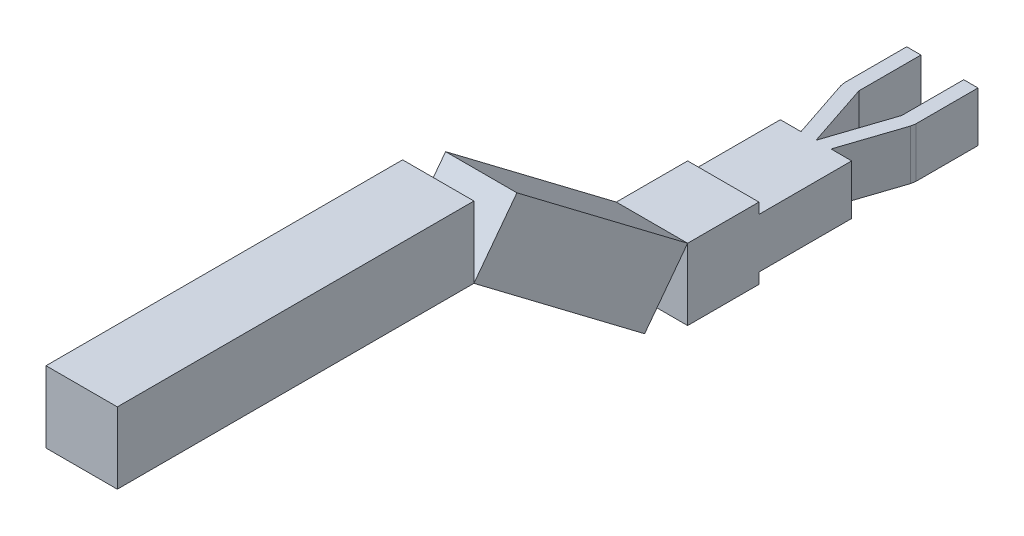
from build123d import *

# Parameters (mm, degrees)
BOSS_EXTRUDE1_DEPTH = 70
SKETCH2_W           = 100
SKETCH2_H           = 100
BOSS_EXTRUDE2_DEPTH = 100
BOSS_EXTRUDE3_DEPTH = 100
SKETCH4_W           = 500
SKETCH4_H           = 100
BOSS_EXTRUDE4_DEPTH = 100


with BuildPart() as part:
    # Sketch1 → Boss-Extrude1 (new body)
    with BuildSketch(Plane(origin=(0, 0, 0), x_dir=(1, 0, 0), z_dir=(0, 1, 0))):
        Polygon((0, -105.768782521), (-30, -15.630000635), (-30, 71.369999365), (-50, 71.369999365), (-50, -15.630000635), (-48.97658566, -21.945790108), (-21.078607457, -105.768782521), (-50, -105.768782521), (-50, -235.768782521), (50, -235.768782521), (50, -105.768782521), (21.078607457, -105.768782521), (48.97658566, -21.945790108), (50, -15.630000635), (50, 71.369999365), (30, 71.369999365), (30, -15.630000635), align=None)
    extrude(amount=BOSS_EXTRUDE1_DEPTH)

    # Sketch2 → Boss-Extrude2 (add)
    with BuildSketch(Plane.XY.offset(235.768782521)):
        with Locations((0, 35)):
            Rectangle(SKETCH2_W, SKETCH2_H)
    extrude(amount=BOSS_EXTRUDE2_DEPTH)


with BuildPart() as body_2:
    # Sketch3 → Boss-Extrude3 (new body)
    with BuildSketch(Plane.ZY.offset(50)):
        Polygon((335.768782521, 85), (396.06206918, 5.220807325), (635.399647205, 186.100667301), (575.106360546, 265.879859976), align=None)
    extrude(amount=-BOSS_EXTRUDE3_DEPTH)


with BuildPart() as body_3:
    # Sketch4 → Boss-Extrude4 (new body)
    with BuildSketch(Plane.ZY.offset(50)):
        with Locations((885.399647205, 236.100667301)):
            Rectangle(SKETCH4_W, SKETCH4_H)
    extrude(amount=-BOSS_EXTRUDE4_DEPTH)


solid = Compound([part.part, body_2.part, body_3.part])
